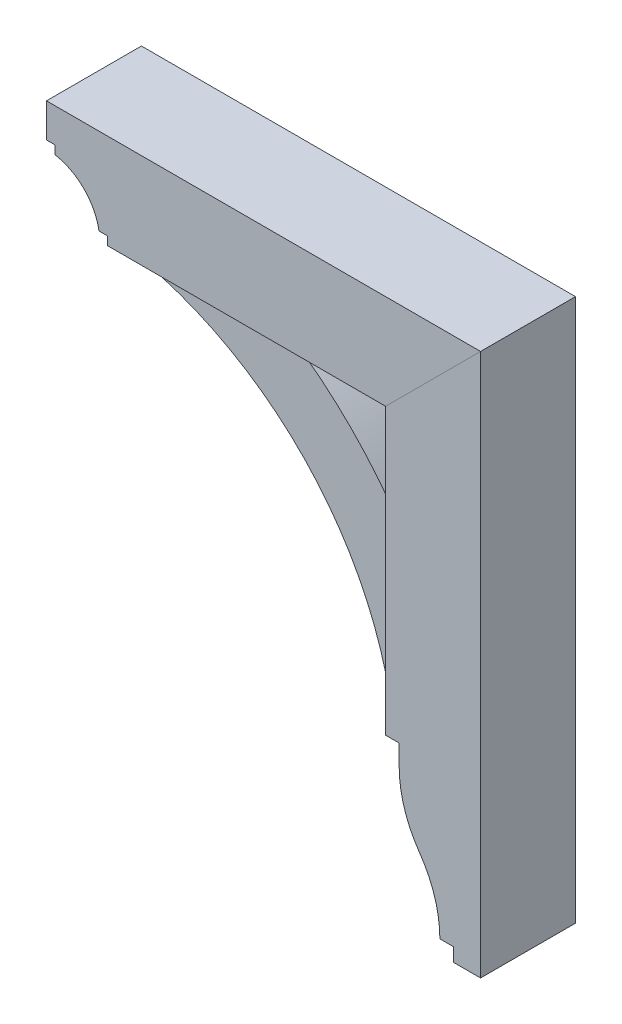
from build123d import *

# Parameters (mm, degrees)
BOSS_EXTRUDE1_DEPTH = 44.45
BOSS_EXTRUDE2_DEPTH = 31.75
BOSS_EXTRUDE3_DEPTH = 44.45


with BuildPart() as part:
    # Sketch1 → Boss-Extrude1 (new body, symmetric)
    with BuildSketch(Plane.XY):
        with BuildLine():
            Line((-75.381276984, 132.3975), (-75.381276984, 140.335))
            Line((-75.381276984, 140.335), (-83.318776984, 140.335))
            Line((-83.318776984, 140.335), (-83.318776984, 172.085))
            Line((-83.318776984, 172.085), (323.081223016, 172.085))
            Line((323.081223016, 172.085), (234.181223016, 83.185))
            Line((234.181223016, 83.185), (-26.168776984, 83.185))
            Line((-26.168776984, 83.185), (-26.168776984, 91.1225))
            Line((-26.168776984, 91.1225), (-34.106276984, 91.1225))
            ThreePointArc((-34.106276984, 91.1225), (-48.213203493, 118.290573491), (-75.381276984, 132.3975))
        make_face()
    extrude(amount=BOSS_EXTRUDE1_DEPTH, both=True)


with BuildPart() as body_2:
    # Sketch1_3 → Boss-Extrude2 (new body, symmetric)
    with BuildSketch(Plane.XY):
        with BuildLine():
            ThreePointArc((234.181223016, -18.415), (188.38389644, 37.387673425), (132.581223016, 83.185))
            Line((132.581223016, 83.185), (11.931223016, 83.185))
            Line((11.931223016, 83.185), (11.931223016, 70.485))
            ThreePointArc((11.931223016, 70.485), (145.202260763, -9.80708101), (221.481223016, -145.415))
            Line((221.481223016, -145.415), (234.181223016, -145.415))
            Line((234.181223016, -145.415), (234.181223016, -18.415))
        make_face()
    extrude(amount=BOSS_EXTRUDE2_DEPTH, both=True)


with BuildPart() as body_3:
    # Sketch1_4 → Boss-Extrude3 (new body, symmetric)
    with BuildSketch(Plane.XY):
        with BuildLine():
            Line((323.081223016, -335.915), (323.081223016, 172.085))
            Line((323.081223016, 172.085), (234.181223016, 83.185))
            Line((234.181223016, 83.185), (234.181223016, -183.515))
            Line((234.181223016, -183.515), (246.881223016, -183.515))
            Line((246.881223016, -183.515), (246.881223016, -202.565))
            ThreePointArc((246.881223016, -202.565), (251.744599276, -234.116039076), (265.883238129, -262.738047859))
            ThreePointArc((265.883238129, -262.738047859), (280.093284249, -291.504612242), (284.981223016, -323.215))
            Line((284.981223016, -323.215), (297.681223016, -323.215))
            Line((297.681223016, -323.215), (297.681223016, -335.915))
            Line((297.681223016, -335.915), (323.081223016, -335.915))
        make_face()
    extrude(amount=BOSS_EXTRUDE3_DEPTH, both=True)


solid = Compound([part.part, body_2.part, body_3.part])
